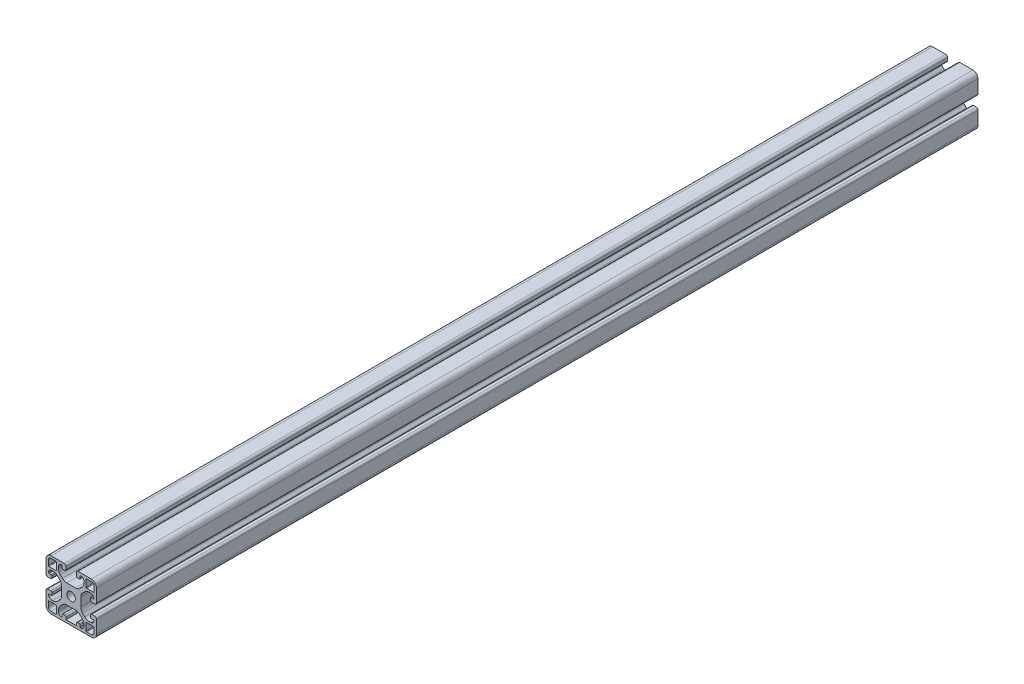
from build123d import *

# Parameters (mm, degrees)
SKIZZE1_R                       = 3.35
AUFSATZ_LINEAR_AUSTRAGEN1_DEPTH = 700


with BuildPart() as part:
    # Skizze1 → Aufsatz-Linear austragen1 (new body)
    with BuildSketch(Plane.XY.offset(1000)):
        with BuildLine():
            Line((5.899999985, 34.292388165), (5.899999985, 35.500000003))
            ThreePointArc((5.899999985, 35.500000003), (6.632233037, 37.267766961), (8.399999999, 38.000000003))
            ThreePointArc((8.399999999, 38.000000003), (8.753553388, 37.853553393), (8.899999996, 37.500000003))
            Line((8.899999996, 37.500000003), (8.899999996, 35.850000004))
            ThreePointArc((8.899999996, 35.850000004), (9.046446605, 35.496446613), (9.399999996, 35.350000004))
            Line((9.399999996, 35.350000004), (10.899999947, 35.350000004))
            ThreePointArc((10.899999947, 35.350000004), (11.607106728, 35.642893223), (11.899999947, 36.350000004))
            Line((11.899999947, 36.350000004), (11.899999947, 38.500000016))
            ThreePointArc((11.899999947, 38.500000016), (11.460660119, 39.560660188), (10.399999947, 40.000000016))
            Line((10.399999947, 40.000000016), (5.2e-08, 40.000000016))
            ThreePointArc((5.2e-08, 40.000000016), (-2.828427117, 38.828427123), (-4.000000011, 35.999999954))
            Line((-4.000000011, 35.999999954), (-4.000000011, 25.599999996))
            ThreePointArc((-4.000000011, 25.599999996), (-3.560660183, 24.539339825), (-2.500000012, 24.099999997))
            Line((-2.500000012, 24.099999997), (-0.350000011, 24.099999997))
            ThreePointArc((-0.350000011, 24.099999997), (0.35710677, 24.392893216), (0.649999989, 25.099999997))
            Line((0.649999989, 25.099999997), (0.649999989, 26.599999997))
            ThreePointArc((0.649999989, 26.599999997), (0.50355338, 26.953553387), (0.149999989, 27.099999997))
            Line((0.149999989, 27.099999997), (-1.500000011, 27.099999997))
            ThreePointArc((-1.500000011, 27.099999997), (-1.853553401, 27.246446605), (-2.000000011, 27.599999993))
            ThreePointArc((-2.000000011, 27.599999993), (-1.26776697, 29.367766957), (0.499999989, 30.10000001))
            Line((0.499999989, 30.10000001), (1.707611833, 30.10000001))
            ThreePointArc((1.707611833, 30.10000001), (3.621028995, 29.719397673), (5.243145739, 28.635533916))
            Line((5.243145739, 28.635533916), (6.935533894, 26.943145761))
            ThreePointArc((6.935533894, 26.943145761), (8.01939765, 25.321029017), (8.399999988, 23.407611855))
            Line((8.399999988, 23.407611855), (8.399999988, 16.592388122))
            ThreePointArc((8.399999988, 16.592388122), (8.01939765, 14.678970961), (6.935533894, 13.056854217))
            Line((6.935533894, 13.056854217), (5.243145737, 11.36446606))
            ThreePointArc((5.243145737, 11.36446606), (3.621028993, 10.280602303), (1.707611831, 9.899999966))
            Line((1.707611831, 9.899999966), (0.49999999, 9.899999966))
            ThreePointArc((0.49999999, 9.899999966), (-1.267766968, 10.632233018), (-2.00000001, 12.399999979))
            ThreePointArc((-2.00000001, 12.399999979), (-1.8535534, 12.753553368), (-1.50000001, 12.899999977))
            Line((-1.50000001, 12.899999977), (0.149999989, 12.899999977))
            ThreePointArc((0.149999989, 12.899999977), (0.50355338, 13.046446586), (0.649999989, 13.399999977))
            Line((0.649999989, 13.399999977), (0.649999989, 14.899999976))
            ThreePointArc((0.649999989, 14.899999976), (0.35710677, 15.607106757), (-0.350000011, 15.899999976))
            Line((-0.350000011, 15.899999976), (-2.50000001, 15.899999976))
            ThreePointArc((-2.50000001, 15.899999976), (-3.560660182, 15.460660148), (-4.000000011, 14.399999976))
            Line((-4.000000011, 14.399999976), (-4.000000011, 4.000000069))
            ThreePointArc((-4.000000011, 4.000000069), (-2.828427121, 1.171572909), (4e-08, 1.9e-08))
            Line((4e-08, 1.9e-08), (31.999999925, 1.9e-08))
            ThreePointArc((31.999999925, 1.9e-08), (34.828427086, 1.171572909), (35.999999976, 4.00000007))
            Line((35.999999976, 4.00000007), (35.999999976, 14.399999977))
            ThreePointArc((35.999999976, 14.399999977), (35.560660149, 15.460660148), (34.499999978, 15.899999976))
            Line((34.499999978, 15.899999976), (32.349999991, 15.899999976))
            ThreePointArc((32.349999991, 15.899999976), (31.642893209, 15.607106757), (31.34999999, 14.899999976))
            Line((31.34999999, 14.899999976), (31.34999999, 13.399999977))
            ThreePointArc((31.34999999, 13.399999977), (31.4964466, 13.046446586), (31.84999999, 12.899999977))
            Line((31.84999999, 12.899999977), (33.499999991, 12.899999977))
            ThreePointArc((33.499999991, 12.899999977), (33.853553381, 12.753553368), (33.999999991, 12.399999979))
            ThreePointArc((33.999999991, 12.399999979), (33.267766949, 10.632233018), (31.499999991, 9.899999966))
            Line((31.499999991, 9.899999966), (30.292388185, 9.899999966))
            ThreePointArc((30.292388185, 9.899999966), (28.378971023, 10.280602303), (26.756854279, 11.36446606))
            Line((26.756854279, 11.36446606), (25.064466082, 13.056854257))
            ThreePointArc((25.064466082, 13.056854257), (23.980602325, 14.678971001), (23.599999988, 16.592388163))
            Line((23.599999988, 16.592388163), (23.599999988, 23.407611842))
            ThreePointArc((23.599999988, 23.407611842), (23.980602325, 25.321029004), (25.064466082, 26.943145747))
            Line((25.064466082, 26.943145747), (26.75685425, 28.635533916))
            ThreePointArc((26.75685425, 28.635533916), (28.378970995, 29.719397673), (30.292388156, 30.10000001))
            Line((30.292388156, 30.10000001), (31.499999989, 30.10000001))
            ThreePointArc((31.499999989, 30.10000001), (33.267766948, 29.367766957), (33.999999989, 27.599999993))
            ThreePointArc((33.999999989, 27.599999993), (33.853553379, 27.246446605), (33.499999989, 27.099999997))
            Line((33.499999989, 27.099999997), (31.84999999, 27.099999997))
            ThreePointArc((31.84999999, 27.099999997), (31.4964466, 26.953553387), (31.34999999, 26.599999997))
            Line((31.34999999, 26.599999997), (31.34999999, 25.099999997))
            ThreePointArc((31.34999999, 25.099999997), (31.642893209, 24.392893216), (32.34999999, 24.099999997))
            Line((32.34999999, 24.099999997), (34.499999976, 24.099999997))
            ThreePointArc((34.499999976, 24.099999997), (35.560660148, 24.539339825), (35.999999976, 25.599999997))
            Line((35.999999976, 25.599999997), (35.999999976, 35.999999953))
            ThreePointArc((35.999999976, 35.999999953), (34.828427083, 38.828427123), (31.999999914, 40.000000016))
            Line((31.999999914, 40.000000016), (21.600000015, 40.000000016))
            ThreePointArc((21.600000015, 40.000000016), (20.539339844, 39.560660188), (20.100000016, 38.500000017))
            Line((20.100000016, 38.500000017), (20.100000016, 36.350000004))
            ThreePointArc((20.100000016, 36.350000004), (20.392893235, 35.642893223), (21.100000017, 35.350000004))
            Line((21.100000017, 35.350000004), (22.600000014, 35.350000004))
            ThreePointArc((22.600000014, 35.350000004), (22.953553405, 35.496446613), (23.100000014, 35.850000004))
            Line((23.100000014, 35.850000004), (23.100000014, 37.500000007))
            ThreePointArc((23.100000014, 37.500000007), (23.246446625, 37.8535534), (23.600000019, 38.000000007))
            ThreePointArc((23.600000019, 38.000000007), (25.367766955, 37.267766951), (26.099999992, 35.500000007))
            Line((26.099999992, 35.500000007), (26.099999992, 34.292388127))
            ThreePointArc((26.099999992, 34.292388127), (25.719397655, 32.378970966), (24.635533898, 30.756854221))
            Line((24.635533898, 30.756854221), (22.943145779, 29.064466103))
            ThreePointArc((22.943145779, 29.064466103), (21.321029035, 27.980602346), (19.407611873, 27.600000009))
            Line((19.407611873, 27.600000009), (12.592388142, 27.600000009))
            ThreePointArc((12.592388142, 27.600000009), (10.678970981, 27.980602346), (9.056854237, 29.064466102))
            Line((9.056854237, 29.064466102), (7.36446608, 30.75685426))
            ThreePointArc((7.36446608, 30.75685426), (6.280602323, 32.378971004), (5.899999985, 34.292388165))
        make_face()
        with Locations((15.999999985, 20)):
            Circle(SKIZZE1_R, mode=Mode.SUBTRACT)
        with BuildLine():
            Line((27.799999996, 32.299999708), (27.799999996, 37.700000083))
            ThreePointArc((27.799999996, 37.700000083), (27.946446591, 38.053553439), (28.299999947, 38.200000034))
            Line((28.299999947, 38.200000034), (31.999999914, 38.200000034))
            ThreePointArc((31.999999914, 38.200000034), (33.555634889, 37.555634929), (34.199999994, 35.999999953))
            Line((34.199999994, 35.999999953), (34.199999994, 32.300000046))
            ThreePointArc((34.199999994, 32.300000046), (34.053553382, 31.946446648), (33.699999983, 31.800000035))
            Line((33.699999983, 31.800000035), (28.299999669, 31.800000035))
            ThreePointArc((28.299999669, 31.800000035), (27.94644651, 31.946446549), (27.799999996, 32.299999708))
        make_face(mode=Mode.SUBTRACT)
        with BuildLine():
            Line((28.299999669, 8.199999998), (33.700000043, 8.199999998))
            ThreePointArc((33.700000043, 8.199999998), (34.053553399, 8.053553402), (34.199999994, 7.700000046))
            Line((34.199999994, 7.700000046), (34.199999994, 4.00000007))
            ThreePointArc((34.199999994, 4.00000007), (33.555634893, 2.444365103), (31.999999925, 1.800000001))
            Line((31.999999925, 1.800000001), (28.300000007, 1.800000001))
            ThreePointArc((28.300000007, 1.800000001), (27.946446609, 1.946446613), (27.799999996, 2.300000012))
            Line((27.799999996, 2.300000012), (27.799999996, 7.700000324))
            ThreePointArc((27.799999996, 7.700000324), (27.94644651, 8.053553484), (28.299999669, 8.199999998))
        make_face(mode=Mode.SUBTRACT)
        with BuildLine():
            Line((3.700000285, 31.800000035), (-1.700000077, 31.800000035))
            ThreePointArc((-1.700000077, 31.800000035), (-2.053553433, 31.94644663), (-2.200000029, 32.299999986))
            Line((-2.200000029, 32.299999986), (-2.200000029, 35.999999954))
            ThreePointArc((-2.200000029, 35.999999954), (-1.555634924, 37.555634929), (5.2e-08, 38.200000034))
            Line((5.2e-08, 38.200000034), (3.699999947, 38.200000034))
            ThreePointArc((3.699999947, 38.200000034), (4.053553346, 38.053553422), (4.199999959, 37.700000023))
            Line((4.199999959, 37.700000023), (4.199999959, 32.299999708))
            ThreePointArc((4.199999959, 32.299999708), (4.053553445, 31.946446549), (3.700000285, 31.800000035))
        make_face(mode=Mode.SUBTRACT)
        with BuildLine():
            Line((4.199999959, 7.700000324), (4.199999959, 2.299999952))
            ThreePointArc((4.199999959, 2.299999952), (4.053553363, 1.946446596), (3.700000007, 1.800000001))
            Line((3.700000007, 1.800000001), (4e-08, 1.800000001))
            ThreePointArc((4e-08, 1.800000001), (-1.555634927, 2.444365102), (-2.200000029, 4.000000069))
            Line((-2.200000029, 4.000000069), (-2.200000029, 7.699999986))
            ThreePointArc((-2.200000029, 7.699999986), (-2.053553416, 8.053553385), (-1.700000017, 8.199999998))
            Line((-1.700000017, 8.199999998), (3.700000285, 8.199999998))
            ThreePointArc((3.700000285, 8.199999998), (4.053553445, 8.053553484), (4.199999959, 7.700000324))
        make_face(mode=Mode.SUBTRACT)
        with BuildLine():
            Line((20.100000016, 2.000000008), (11.899999947, 2.000000008))
            Line((11.899999947, 2.000000008), (11.899999947, 3.649999992))
            ThreePointArc((11.899999947, 3.649999992), (11.607106728, 4.357106773), (10.899999947, 4.649999992))
            Line((10.899999947, 4.649999992), (9.399999996, 4.649999992))
            ThreePointArc((9.399999996, 4.649999992), (9.046446606, 4.503553382), (8.899999996, 4.149999992))
            Line((8.899999996, 4.149999992), (8.899999996, 2.499999991))
            ThreePointArc((8.899999996, 2.499999991), (8.753553389, 2.146446604), (8.400000003, 1.999999994))
            ThreePointArc((8.400000003, 1.999999994), (6.632233039, 2.732233035), (5.899999985, 4.499999994))
            Line((5.899999985, 4.499999994), (5.899999985, 5.707611838))
            ThreePointArc((5.899999985, 5.707611838), (6.280602323, 7.621029001), (7.36446608, 9.243145746))
            Line((7.36446608, 9.243145746), (9.056854238, 10.935533903))
            ThreePointArc((9.056854238, 10.935533903), (10.678970982, 12.01939766), (12.592388143, 12.399999997))
            Line((12.592388143, 12.399999997), (19.407611847, 12.399999997))
            ThreePointArc((19.407611847, 12.399999997), (21.321029008, 12.01939766), (22.943145752, 10.935533904))
            Line((22.943145752, 10.935533904), (24.635533898, 9.243145757))
            ThreePointArc((24.635533898, 9.243145757), (25.719397655, 7.621029013), (26.099999992, 5.707611851))
            Line((26.099999992, 5.707611851), (26.099999992, 4.499999993))
            ThreePointArc((26.099999992, 4.499999993), (25.367766954, 2.73223305), (23.600000019, 1.999999995))
            ThreePointArc((23.600000019, 1.999999995), (23.246446625, 2.146446603), (23.100000014, 2.499999995))
            Line((23.100000014, 2.499999995), (23.100000014, 4.149999994))
            ThreePointArc((23.100000014, 4.149999994), (22.953553405, 4.503553383), (22.600000016, 4.649999992))
            Line((22.600000016, 4.649999992), (21.100000017, 4.649999992))
            ThreePointArc((21.100000017, 4.649999992), (20.392893235, 4.357106773), (20.100000016, 3.649999992))
            Line((20.100000016, 3.649999992), (20.100000016, 2.000000008))
        make_face(mode=Mode.SUBTRACT)
    extrude(amount=-AUFSATZ_LINEAR_AUSTRAGEN1_DEPTH)


solid = part.part
